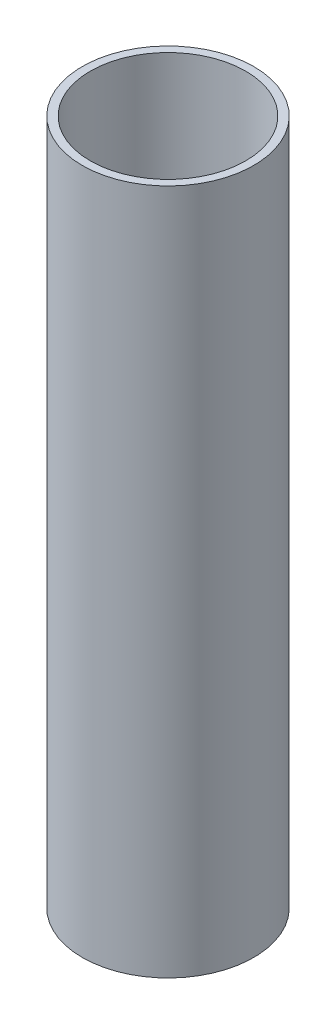
from build123d import *

# Parameters (mm, degrees)
SKETCH1_R           = 9.525
SKETCH1_R_2         = 8.636
BOSS_EXTRUDE1_DEPTH = 38.1


with BuildPart() as part:
    # Sketch1 → Boss-Extrude1 (new body, symmetric)
    with BuildSketch(Plane(origin=(0, 0, 0), x_dir=(1, 0, 0), z_dir=(0, 1, 0))):
        Circle(SKETCH1_R)
        Circle(SKETCH1_R_2, mode=Mode.SUBTRACT)
    extrude(amount=BOSS_EXTRUDE1_DEPTH, both=True)


solid = part.part
